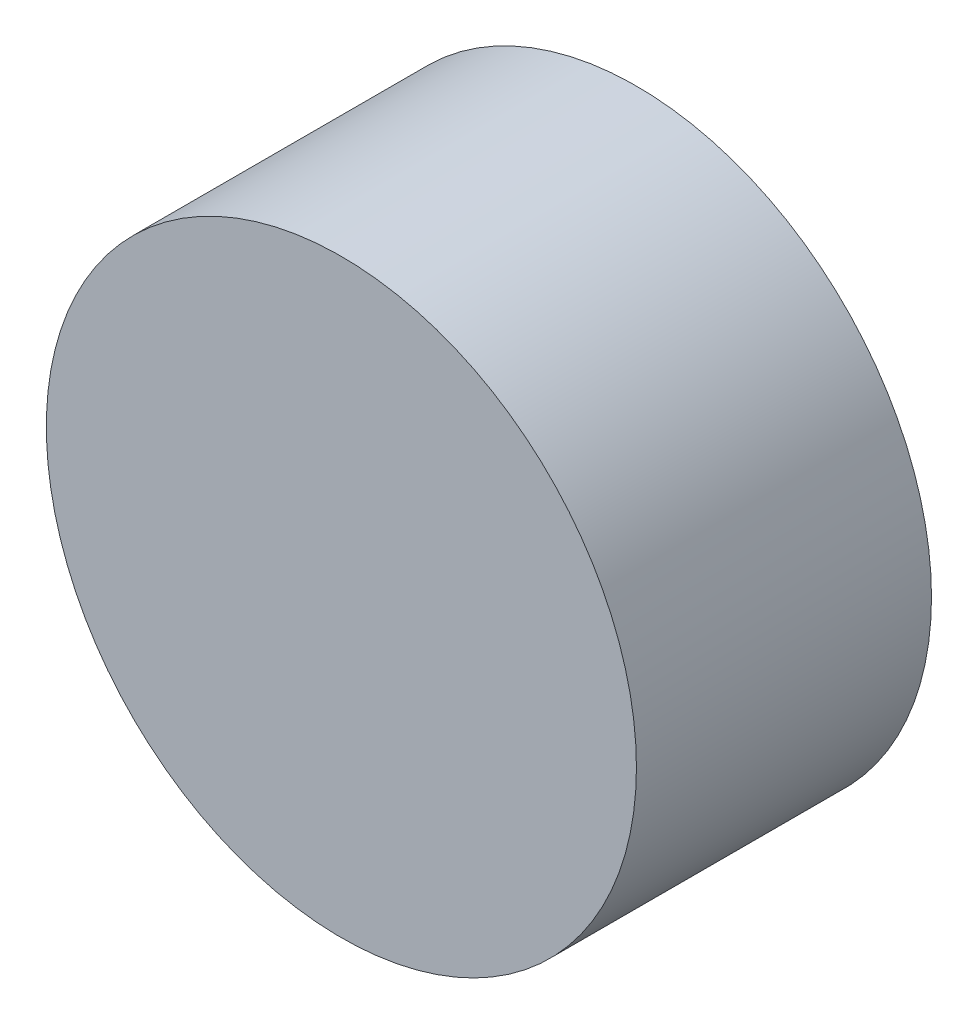
from build123d import *

# Parameters (mm, degrees)
SKETCH_1_R      = 30
EXTRUDE_1_DEPTH = 30


with BuildPart() as part:
    # 草圖1 → 填料-伸長1 (new body)
    with BuildSketch(Plane.XY):
        Circle(SKETCH_1_R)
    extrude(amount=EXTRUDE_1_DEPTH)


solid = part.part
